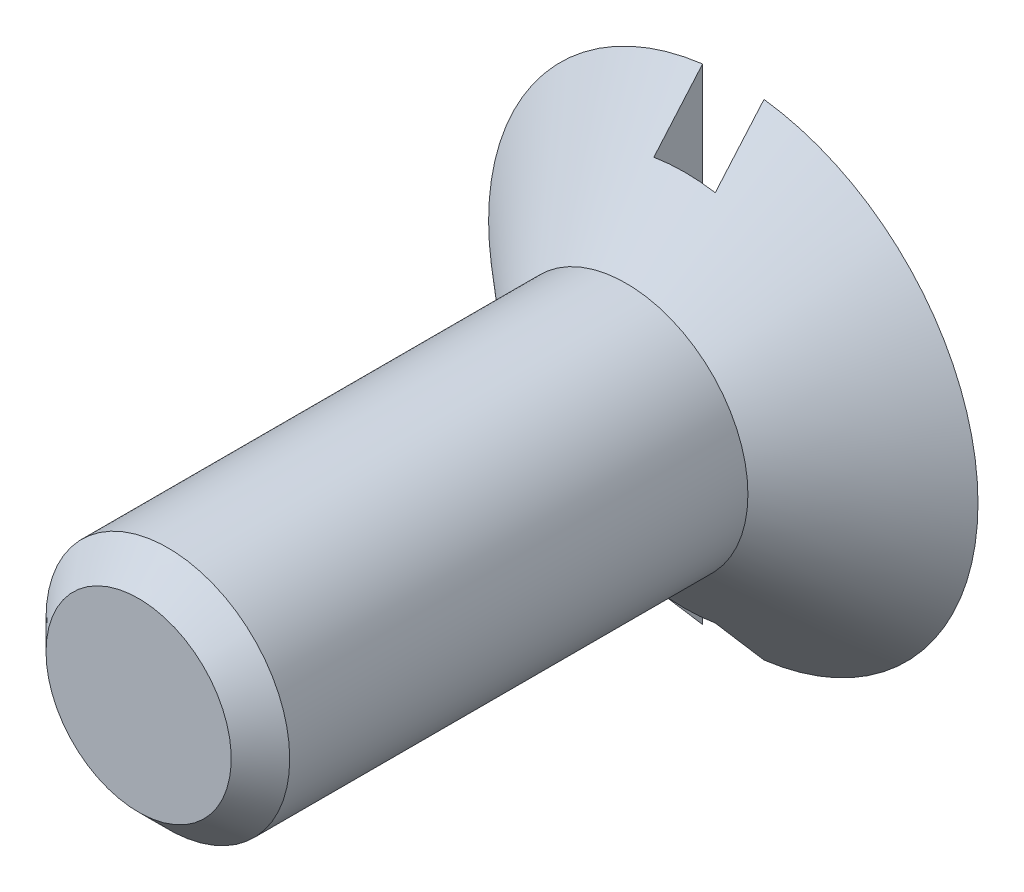
from build123d import *

# Parameters (mm, degrees)
SKETCH6_W          = 1.6002
SKETCH6_H          = 14.426568413
CUT_EXTRUDE2_DEPTH = 1.27


with BuildPart() as part:
    # Sketch5 → Revolve2 (revolve)
    with BuildSketch(Plane(origin=(0, 0, 0), x_dir=(1, 0, 0), z_dir=(0, 1, 0))):
        Polygon((0, 14.732), (0, -0.762), (2.413, -0.762), (3.175, 0), (3.175, 11.938), (6.3754, 14.732), align=None)
    revolve(axis=Axis((0, 0, 0), (0, 0, 1)))

    # Sketch6 → Cut-Extrude2 (cut)
    with BuildSketch(Plane(origin=(0, 0, -14.732), x_dir=(-1, 0, 0), z_dir=(0, 0, -1))):
        with Locations((0, 0.400071831)):
            Rectangle(SKETCH6_W, SKETCH6_H)
    extrude(amount=-CUT_EXTRUDE2_DEPTH, mode=Mode.SUBTRACT)


solid = part.part
